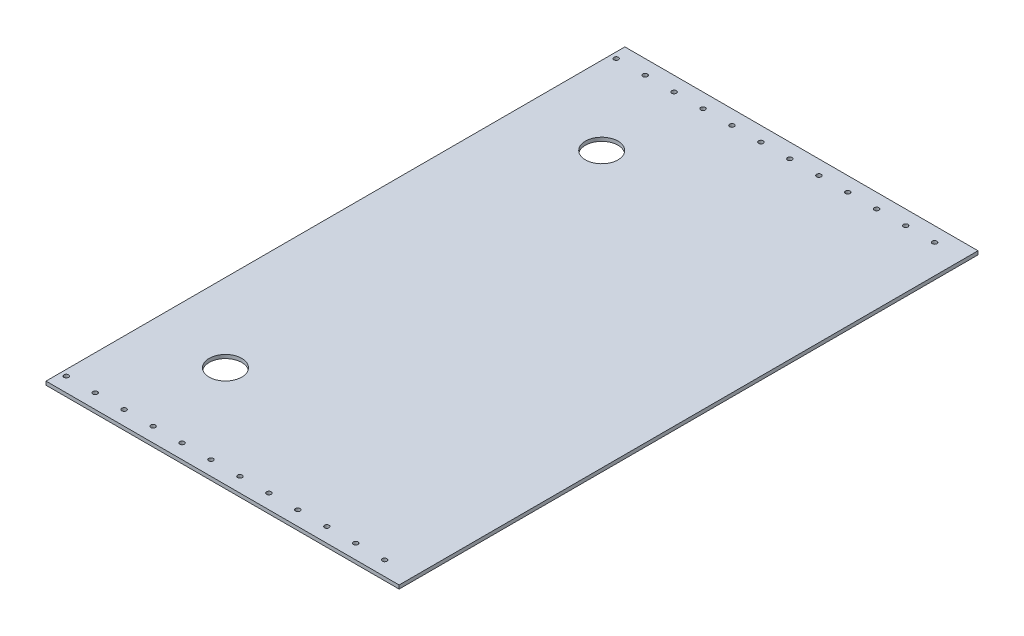
from build123d import *

# Parameters (mm, degrees)
SKETCH1_W               = 571.5
SKETCH1_H               = 508
BOSS_EXTRUDE1_DEPTH     = 3.175
SKETCH2_R               = 14.2875
CUT_EXTRUDE1_DEPTH      = 3.175
SKETCH4_R               = 2.0193
CUT_EXTRUDE3_DEPTH      = 1
CUT_EXTRUDE3_DEPTH_BACK = 4.175
SKETCH5_W               = 619.579537293
SKETCH5_H               = 89.035098343
CUT_EXTRUDE4_DEPTH      = 165.1
SKETCH6_W               = 508
SKETCH6_H               = 3.175
CUT_EXTRUDE5_DEPTH      = 96.52


with BuildPart() as part:
    # Sketch1 → Boss-Extrude1 (new body)
    with BuildSketch(Plane(origin=(0, 0, 0), x_dir=(1, 0, 0), z_dir=(0, 1, 0))):
        with Locations((285.75, 254)):
            Rectangle(SKETCH1_W, SKETCH1_H)
    extrude(amount=BOSS_EXTRUDE1_DEPTH)

    # Sketch2 → Cut-Extrude1 (cut)
    with BuildSketch(Plane(origin=(0, 3.175, 0), x_dir=(1, 0, 0), z_dir=(0, 1, 0))):
        with Locations((330.2, 419.1)):
            Circle(SKETCH2_R)
        with Locations((330.2, 88.9)):
            Circle(SKETCH2_R)
    extrude(amount=-CUT_EXTRUDE1_DEPTH, mode=Mode.SUBTRACT)

    # Sketch4 → Cut-Extrude3 (cut, two sides)
    with BuildSketch(Plane(origin=(0, 3.175, 0), x_dir=(1, 0, 0), z_dir=(0, 1, 0))) as cut_extrude3_sk:
        with Locations((546.1, 495.3)):
            Circle(SKETCH4_R)
        with Locations((520.7, 495.3)):
            Circle(SKETCH4_R)
        with Locations((495.3, 495.3)):
            Circle(SKETCH4_R)
        with Locations((469.9, 495.3)):
            Circle(SKETCH4_R)
        with Locations((444.5, 495.3)):
            Circle(SKETCH4_R)
        with Locations((419.1, 495.3)):
            Circle(SKETCH4_R)
        with Locations((393.7, 495.3)):
            Circle(SKETCH4_R)
        with Locations((368.3, 495.3)):
            Circle(SKETCH4_R)
        with Locations((342.9, 495.3)):
            Circle(SKETCH4_R)
        with Locations((317.5, 495.3)):
            Circle(SKETCH4_R)
        with Locations((292.1, 495.3)):
            Circle(SKETCH4_R)
        with Locations((266.7, 495.3)):
            Circle(SKETCH4_R)
        with Locations((228.6, 495.3)):
            Circle(SKETCH4_R)
        with Locations((203.2, 495.3)):
            Circle(SKETCH4_R)
        with Locations((203.2, 12.7)):
            Circle(SKETCH4_R)
        with Locations((228.6, 12.7)):
            Circle(SKETCH4_R)
        with Locations((266.7, 12.7)):
            Circle(SKETCH4_R)
        with Locations((292.1, 12.7)):
            Circle(SKETCH4_R)
        with Locations((317.5, 12.7)):
            Circle(SKETCH4_R)
        with Locations((342.9, 12.7)):
            Circle(SKETCH4_R)
        with Locations((368.3, 12.7)):
            Circle(SKETCH4_R)
        with Locations((393.7, 12.7)):
            Circle(SKETCH4_R)
        with Locations((419.1, 12.7)):
            Circle(SKETCH4_R)
        with Locations((444.5, 12.7)):
            Circle(SKETCH4_R)
        with Locations((469.9, 12.7)):
            Circle(SKETCH4_R)
        with Locations((495.3, 12.7)):
            Circle(SKETCH4_R)
        with Locations((520.7, 12.7)):
            Circle(SKETCH4_R)
        with Locations((546.1, 12.7)):
            Circle(SKETCH4_R)
    extrude(amount=CUT_EXTRUDE3_DEPTH, mode=Mode.SUBTRACT)
    extrude(cut_extrude3_sk.sketch, amount=-CUT_EXTRUDE3_DEPTH_BACK, mode=Mode.SUBTRACT)

    # Sketch5 → Cut-Extrude4 (cut)
    with BuildSketch(Plane.ZY):
        with Locations((-257.641209254, 26.710529503)):
            Rectangle(SKETCH5_W, SKETCH5_H)
    extrude(amount=-CUT_EXTRUDE4_DEPTH, mode=Mode.SUBTRACT)

    # Sketch6 → Cut-Extrude5 (cut)
    with BuildSketch(Plane.ZY.offset(-165.1)):
        with Locations((-254, 1.5875)):
            Rectangle(SKETCH6_W, SKETCH6_H)
    extrude(amount=-CUT_EXTRUDE5_DEPTH, mode=Mode.SUBTRACT)


solid = part.part
